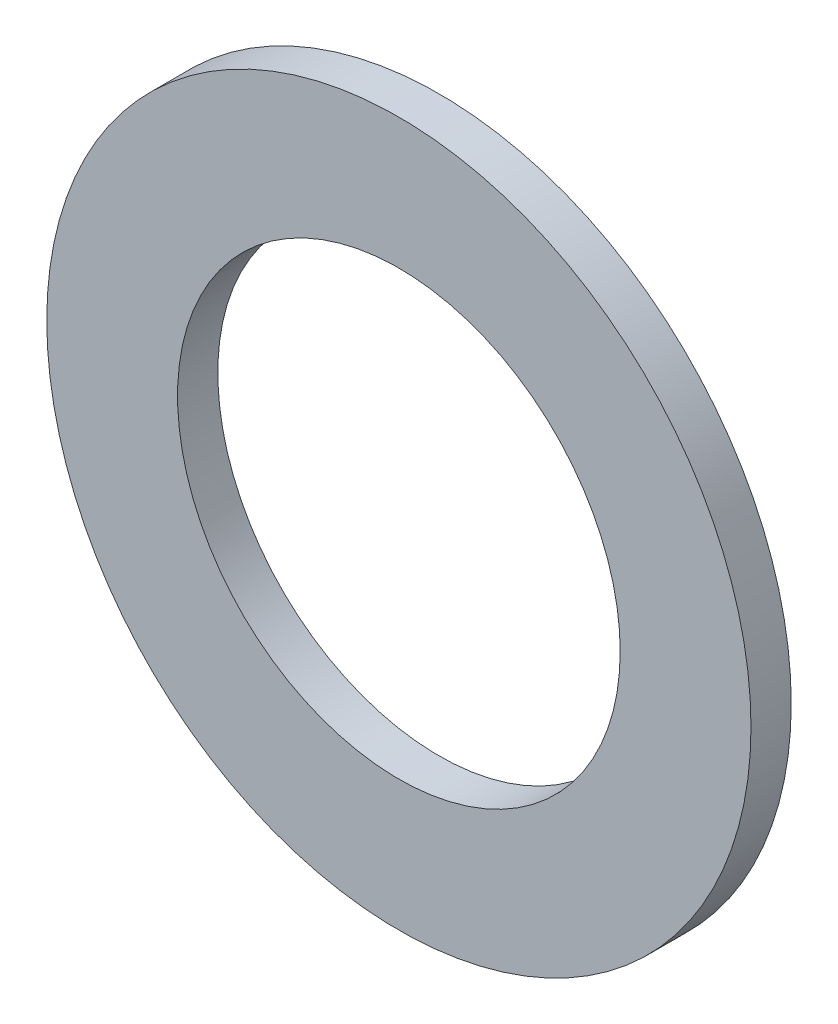
from build123d import *

# Parameters (mm, degrees)
SKETCH_1_R      = 17.5
SKETCH_1_R_2    = 11
EXTRUDE_1_DEPTH = 2


with BuildPart() as part:
    # Эскиз1 → Бобышка-Вытянуть1 (new body)
    with BuildSketch(Plane.XY):
        with Locations((-25, 0)):
            Circle(SKETCH_1_R)
        with Locations((-25, 0)):
            Circle(SKETCH_1_R_2, mode=Mode.SUBTRACT)
    extrude(amount=EXTRUDE_1_DEPTH)


solid = part.part
